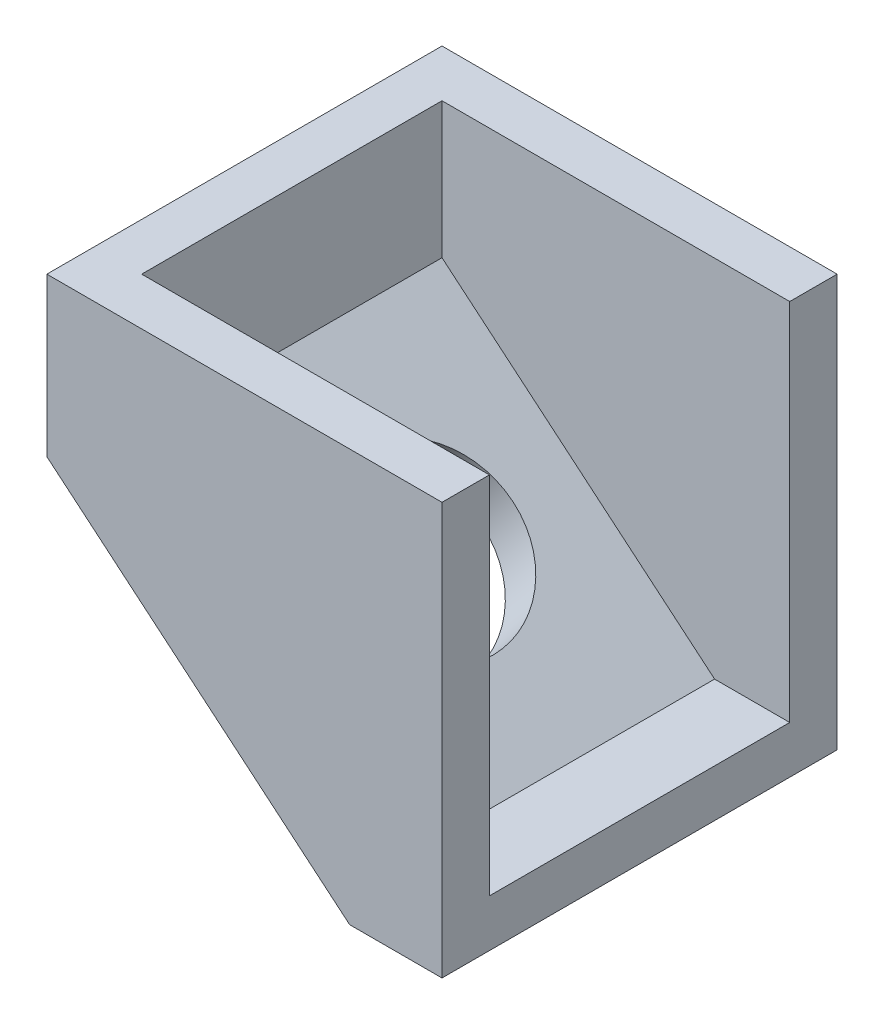
from build123d import *

# Parameters (mm, degrees)
SKETCH1_W           = 50
SKETCH1_H           = 50
BOSS_EXTRUDE1_DEPTH = 52.13
CUT_EXTRUDE1_DEPTH  = 52.13
SKETCH3_W           = 50
SKETCH3_H           = 38
CUT_EXTRUDE2_DEPTH  = 52.13
BOSS_EXTRUDE3_DEPTH = 38
SKETCH5_R           = 11
CUT_EXTRUDE3_DEPTH  = 52.13


with BuildPart() as part:
    # Sketch1 → Boss-Extrude1 (new body)
    with BuildSketch(Plane(origin=(0, 0, 0), x_dir=(1, 0, 0), z_dir=(0, 1, 0))):
        with Locations((25, 25)):
            Rectangle(SKETCH1_W, SKETCH1_H)
    extrude(amount=BOSS_EXTRUDE1_DEPTH)

    # Sketch2 → Cut-Extrude1 (cut)
    with BuildSketch(Plane.XY):
        Polygon((0, 32.13), (0, 0), (38.31009136, 0), align=None)
    extrude(amount=-CUT_EXTRUDE1_DEPTH, mode=Mode.SUBTRACT)

    # Sketch3 → Cut-Extrude2 (cut)
    with BuildSketch(Plane(origin=(0, 52.13, 0), x_dir=(1, 0, 0), z_dir=(0, 1, 0))):
        with Locations((25, 25)):
            Rectangle(SKETCH3_W, SKETCH3_H)
    extrude(amount=-CUT_EXTRUDE2_DEPTH, mode=Mode.SUBTRACT)

    # Sketch4 → Boss-Extrude3 (add)
    with BuildSketch(Plane.XY.offset(-44)):
        Polygon((6, 34.928740389), (6, 52.13), (0, 52.13), (0, 32.13), (38.31009136, 0), (50, 0), (50, 6), (40.493080835, 6), align=None)
    extrude(amount=BOSS_EXTRUDE3_DEPTH)

    # Sketch5 → Cut-Extrude3 (cut)
    with BuildSketch(Plane(origin=(15.819568381, 18.862406161, 0), x_dir=(0.766201827, -0.6426, 0), z_dir=(-0.6426, -0.766201827, 0))):
        with Locations((4.353262, -25)):
            Circle(SKETCH5_R)
    extrude(amount=-CUT_EXTRUDE3_DEPTH, mode=Mode.SUBTRACT)


solid = part.part
